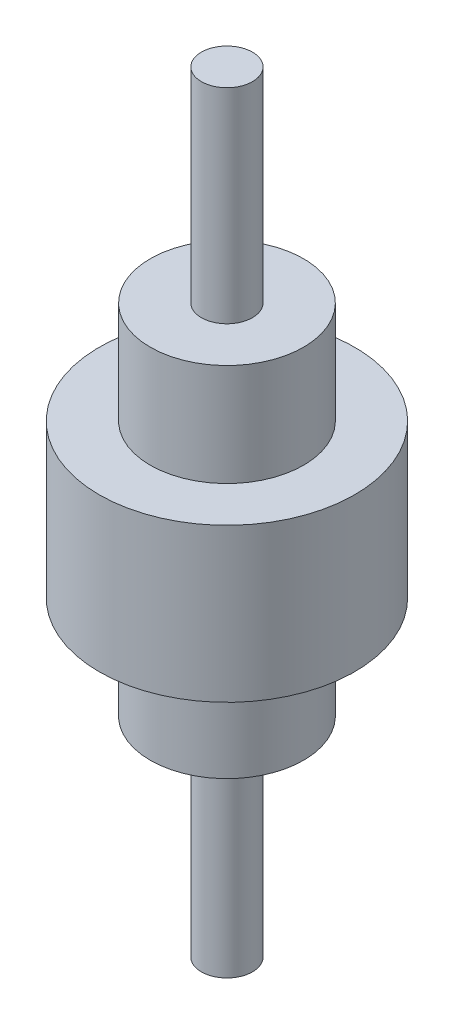
from build123d import *


with BuildPart() as part:
    # Sketch1 → Revolve1 (revolve)
    with BuildSketch(Plane.XY, mode=Mode.PRIVATE) as revolve1_sk:
        Polygon((0, 0), (10, 0), (10, 1.693933425), (10, 81.693933425), (30, 81.693933425), (30, 121.693933425), (50, 121.693933425), (50, 181.693933425), (30, 181.693933425), (30, 221.693933425), (10, 221.693933425), (10, 301.693933425), (0, 301.693933425), align=None)
    revolve(revolve1_sk.sketch.rotate(Axis((0, 99.4903565, 0), (0, -1, 0)), 90), axis=Axis((0, 99.4903565, 0), (0, -1, 0)))  # turned: the seam where the file's is


solid = part.part
